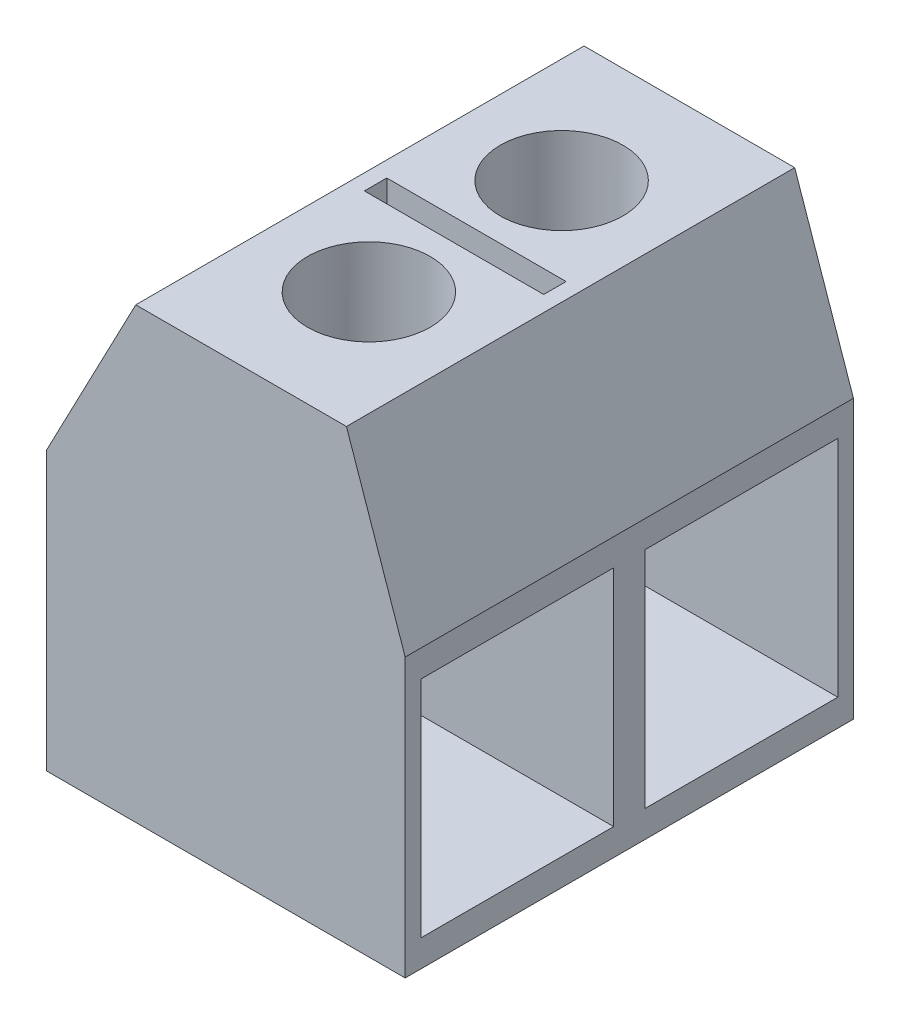
from build123d import *

# Parameters (mm, degrees)
BOSS_EXTRUDE1_DEPTH = 10
SKETCH2_W           = 4.3
SKETCH2_H           = 5
CUT_EXTRUDE1_DEPTH  = 5.3
SKETCH3_R           = 1.368686713
SKETCH3_W           = 4
SKETCH3_H           = 0.5
CUT_EXTRUDE2_DEPTH  = 5


with BuildPart() as part:
    # Sketch1 → Boss-Extrude1 (new body)
    with BuildSketch(Plane.XY):
        Polygon((-3.415220484, 0), (4.584779516, 0), (4.584779516, 6.2), (3.274734062, 10.00055008), (-1.425265938, 10.00055008), (-3.415220484, 6.2), align=None)
    extrude(amount=BOSS_EXTRUDE1_DEPTH)

    # Sketch2 → Cut-Extrude1 (cut)
    with BuildSketch(Plane(origin=(4.584779516, 0, 0), x_dir=(0, 0, -1), z_dir=(1, 0, 0))):
        with Locations((-7.5, 3.1)):
            Rectangle(SKETCH2_W, SKETCH2_H)
        with Locations((-2.5, 3.1)):
            Rectangle(SKETCH2_W, SKETCH2_H)
    extrude(amount=-CUT_EXTRUDE1_DEPTH, mode=Mode.SUBTRACT)

    # Sketch3 → Cut-Extrude2 (cut)
    with BuildSketch(Plane(origin=(0, 10.00055008, 0), x_dir=(1, 0, 0), z_dir=(0, 1, 0))):
        with Locations((0.924734062, -2.85)):
            Circle(SKETCH3_R)
        with Locations((0.924734062, -7.15)):
            Circle(SKETCH3_R)
        with Locations((0.924734062, -5)):
            Rectangle(SKETCH3_W, SKETCH3_H)
    extrude(amount=-CUT_EXTRUDE2_DEPTH, mode=Mode.SUBTRACT)


solid = part.part
